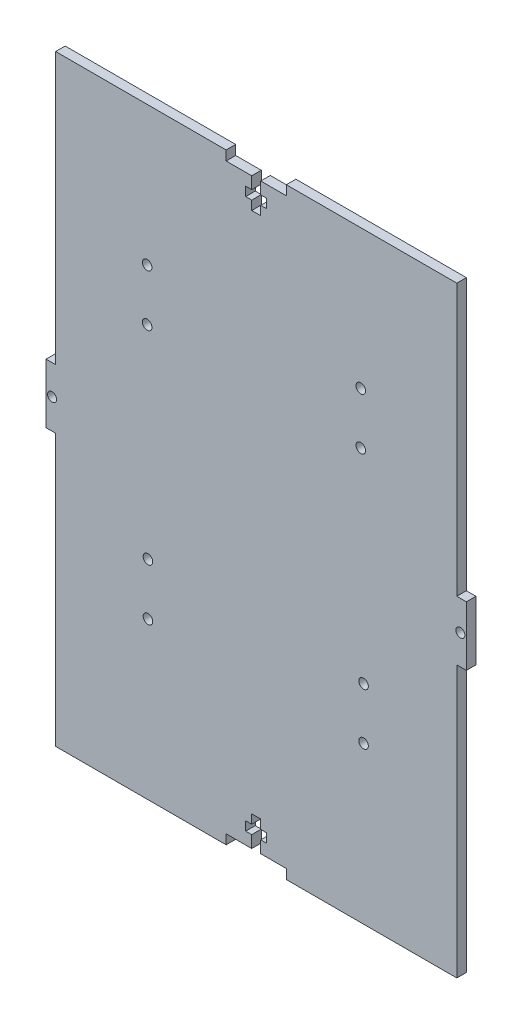
from build123d import *

# Parameters (mm, degrees)
SKETCH1_W           = 139.7
SKETCH1_H           = 200.02
BOSS_EXTRUDE1_DEPTH = 3.18
SKETCH2_R           = 1.5
SKETCH2_W           = 3.18
SKETCH2_H           = 90.135
CUT_EXTRUDE1_DEPTH  = 4.18
SKETCH3_R           = 1.59
CUT_EXTRUDE2_DEPTH  = 4.18
SKETCH4_R           = 1.59
CUT_EXTRUDE3_DEPTH  = 4.18


with BuildPart() as part:
    # Sketch1 → Boss-Extrude1 (new body)
    with BuildSketch(Plane.XY):
        Rectangle(SKETCH1_W, SKETCH1_H)
    extrude(amount=BOSS_EXTRUDE1_DEPTH)

    # Sketch2 → Cut-Extrude1 (cut, through all)
    with BuildSketch(Plane.XY.offset(3.18)):
        with Locations((-67.85, 0)):
            Circle(SKETCH2_R)
        with Locations((67.85, 0)):
            Circle(SKETCH2_R)
        Polygon((-10, 100.01), (10, 100.01), (10, 96.83), (1.5, 96.83), (1.5, 92.83), (3.5, 92.83), (3.5, 89.83), (1.5, 89.83), (1.5, 86.83), (-1.5, 86.83), (-1.5, 89.83), (-3.5, 89.83), (-3.5, 92.83), (-1.5, 92.83), (-1.5, 96.83), (-10, 96.83), align=None)
        Polygon((-10, -100.01), (-10, -96.83), (-1.5, -96.83), (-1.5, -92.83), (-3.5, -92.83), (-3.5, -89.83), (-1.5, -89.83), (-1.5, -86.83), (1.5, -86.83), (1.5, -89.83), (3.5, -89.83), (3.5, -92.83), (1.5, -92.83), (1.5, -96.83), (10, -96.83), (10, -100.01), align=None)
        with Locations((-68.26, 54.9425)):
            Rectangle(SKETCH2_W, SKETCH2_H)
        with Locations((-68.26, -54.9425)):
            Rectangle(SKETCH2_W, SKETCH2_H)
        with Locations((68.26, -54.9425)):
            Rectangle(SKETCH2_W, SKETCH2_H)
        with Locations((68.26, 54.9425)):
            Rectangle(SKETCH2_W, SKETCH2_H)
    extrude(amount=-CUT_EXTRUDE1_DEPTH, mode=Mode.SUBTRACT)

    # Sketch3 → Cut-Extrude2 (cut, through all)
    with BuildSketch(Plane(origin=(0, 0, 0), x_dir=(-1, 0, 0), z_dir=(0, 0, -1))):
        with Locations((-35.67127699, -47.963396943)):
            Circle(SKETCH3_R)
        with Locations((-35.67127699, -30.777287406)):
            Circle(SKETCH3_R)
    extrude(amount=-CUT_EXTRUDE2_DEPTH, mode=Mode.SUBTRACT)

    # Sketch4 → Cut-Extrude3 (cut, through all)
    with BuildSketch(Plane(origin=(0, 0, 0), x_dir=(-1, 0, 0), z_dir=(0, 0, -1))):
        with Locations((-34.750723073, 53.780323187)):
            Circle(SKETCH4_R)
        with Locations((-34.750723073, 36.59421365)):
            Circle(SKETCH4_R)
        with Locations((36.249784221, 53.780323187)):
            Circle(SKETCH4_R)
        with Locations((36.249784221, 36.59421365)):
            Circle(SKETCH4_R)
        with Locations((35.983928162, -30.777287406)):
            Circle(SKETCH4_R)
        with Locations((35.983928162, -47.963396943)):
            Circle(SKETCH4_R)
        with Locations((-35.67127699, -30.777287406)):
            Circle(SKETCH4_R)
        with Locations((-35.67127699, -47.963396943)):
            Circle(SKETCH4_R)
    extrude(amount=-CUT_EXTRUDE3_DEPTH, mode=Mode.SUBTRACT)


solid = part.part
